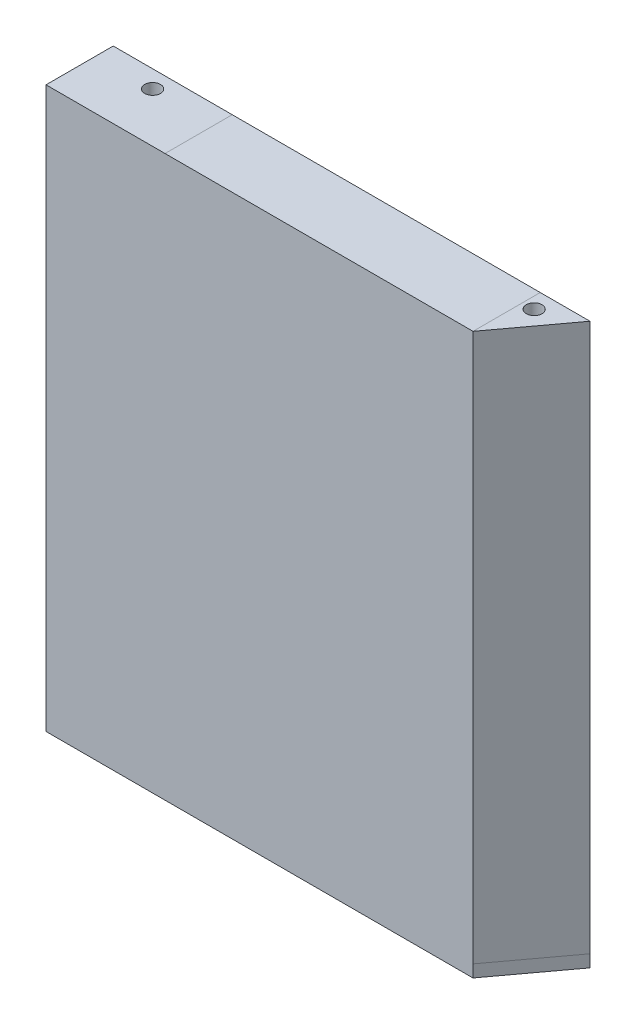
from build123d import *

# Parameters (mm, degrees)
BOSS_EXTRUDE1_DEPTH  = 7
BOSS_EXTRUDE2_DEPTH  = 38.4
BOSS_EXTRUDE3_DEPTH  = 7
BOSS_EXTRUDE4_DEPTH  = 7
BOSS_EXTRUDE13_DEPTH = 306
CUT_EXTRUDE1_DEPTH   = 7
SKETCH7_R            = 4.5
CUT_EXTRUDE2_DEPTH   = 321.010371483


with BuildPart() as part:
    # Sketch1 → Boss-Extrude1 (new body)
    with BuildSketch(Plane.XY.offset(156.4)):
        Polygon((-125.672708569, 154.629250989), (48.327291305, 154.635876502), (50.295177711, 154.635951434), (50.284067725, 147.635951006), (50.284067725, -151.364049211), (-184.661056762, -151.372995372), (-186.670538102, -151.372995372), (-186.670538102, 97.627040708), (-186.670804646, 104.627040714), (-186.670804646, 154.629250989), align=None)
    extrude(amount=BOSS_EXTRUDE1_DEPTH)

    # Sketch2 → Boss-Extrude2 (add)
    with BuildSketch(Plane.XY.offset(163.4)):
        Polygon((-125.67284184, 161.629250989), (-193.670804646, 161.629250989), (-193.670804646, 104.626907443), (-193.670538102, 97.626907437), (-193.670538102, -158.372995372), (-184.660923425, -158.372995372), (50.284067725, -158.364049216), (50.284067725, -151.364049211), (-184.661056762, -151.372995372), (-186.670538102, -151.372995372), (-186.670538102, 97.627040708), (-186.670804646, 104.627040714), (-186.670804646, 154.629250989), (-125.672708569, 154.629250989), (50.295177711, 154.635951434), (50.306287696, 161.635951862), align=None)
    extrude(amount=-BOSS_EXTRUDE2_DEPTH)

    # Sketch4 → Boss-Extrude4 (add)
    with BuildSketch(Plane(origin=(0.006030205, -158.365963686, 0), x_dir=(0.999999999, 3.8078e-05, 0), z_dir=(3.8078e-05, -0.999999999, 0))):
        Polygon((50.278037556, 125), (50.278037556, 163.4), (78.678037556, 125), align=None)
    extrude(amount=-BOSS_EXTRUDE4_DEPTH)

    # Sketch6 → Cut-Extrude1 (cut)
    with BuildSketch(Plane.ZY.offset(193.670538102)):
        with BuildLine():
            add(Edge.make_bspline(
                [(135.76, -114.594279246), (135.76, -128.874279236), (150.04, -128.874279236), (150.04, -114.594279246), (150.04, -100.314279257), (135.76, -100.314279257), (135.76, -114.594279246)],
                knots=[0, 0, 0, 0, 0.5, 0.5, 0.5, 1, 1, 1, 1], degree=3, weights=[1, 0.333333333, 0.333333333, 1, 0.333333333, 0.333333333, 1]))
        make_face()
    extrude(amount=-CUT_EXTRUDE1_DEPTH, mode=Mode.SUBTRACT)


with BuildPart() as body_2:
    # Sketch3 → Boss-Extrude3 (new body)
    with BuildSketch(Plane(origin=(-0.006154646, 161.634036082, 0), x_dir=(0.999999999, 3.8078e-05, 0), z_dir=(-3.8078e-05, 0.999999999, 0))):
        Polygon((50.312442379, -125), (50.312442379, -163.4), (78.712442379, -125), align=None)
    extrude(amount=-BOSS_EXTRUDE3_DEPTH)

    # Sketch5 → Boss-Extrude13 (add)
    with BuildSketch(Plane(origin=(-0.005888102, 154.634036087, 0), x_dir=(0.999999999, 3.8078e-05, 0), z_dir=(3.8078e-05, -0.999999999, 0))):
        Polygon((50.312442379, 163.4), (78.712442379, 125), (73.535352208, 125), (50.312442379, 156.399990755), align=None)
    extrude(amount=BOSS_EXTRUDE13_DEPTH)


with BuildPart() as cut_extrude2_tool:
    # Sketch7 → Cut-Extrude2 (new body, through all)
    with BuildSketch(Plane(origin=(0.006030205, -158.365963686, 0), x_dir=(0.999999999, 3.8078e-05, 0), z_dir=(3.8078e-05, -0.999999999, 0))):
        with Locations((-161.176568435, 135)):
            Circle(SKETCH7_R)
        with Locations((56.823431565, 135)):
            Circle(SKETCH7_R)
    extrude(amount=-CUT_EXTRUDE2_DEPTH)


with BuildPart() as part_1:
    add(part.part)

    # Cut-Extrude2: cut by cut_extrude2_tool
    add(cut_extrude2_tool.part, mode=Mode.SUBTRACT)


with BuildPart() as body_2_1:
    add(body_2.part)

    # Cut-Extrude2: cut by cut_extrude2_tool
    add(cut_extrude2_tool.part, mode=Mode.SUBTRACT)


solid = Compound([part_1.part, body_2_1.part])
